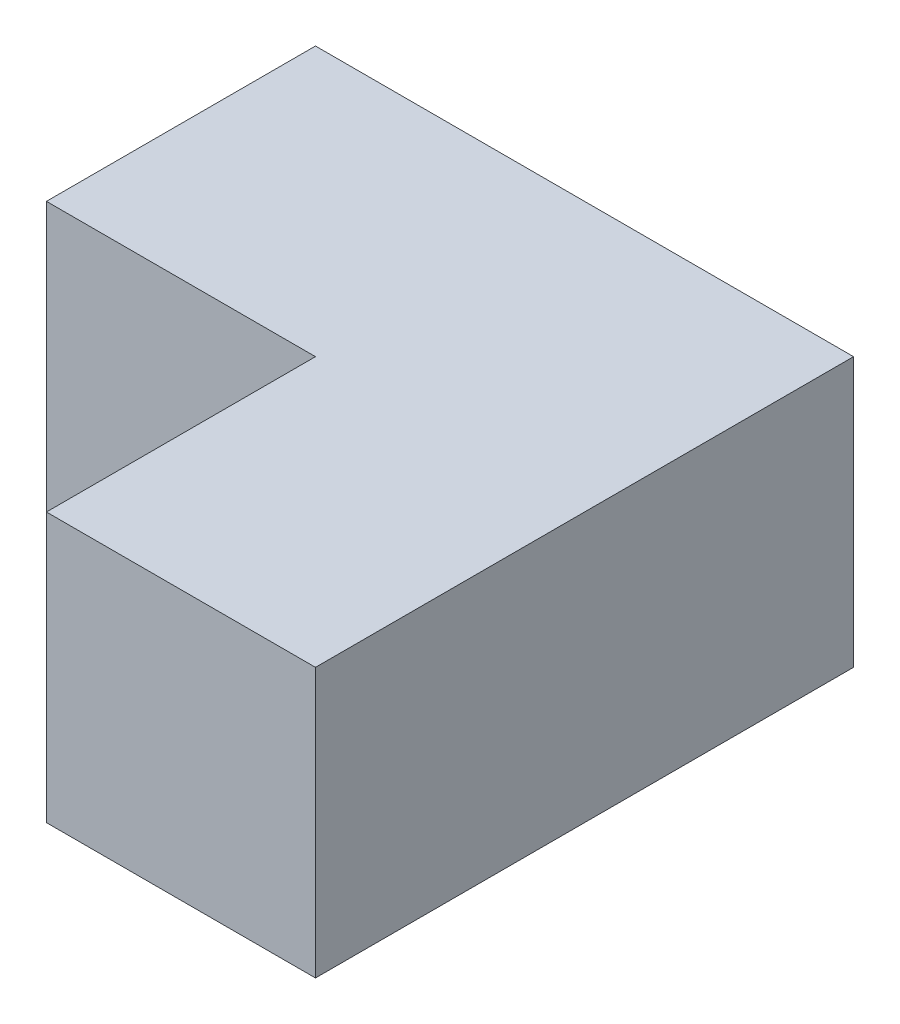
from build123d import *

# Parameters (mm, degrees)
SKETCH1_W           = 50.8
SKETCH1_H           = 50.8
BOSS_EXTRUDE1_DEPTH = 25.4
SKETCH2_W           = 25.4
SKETCH2_H           = 25.4
CUT_EXTRUDE1_DEPTH  = 26.4


with BuildPart() as part:
    # Sketch1 → Boss-Extrude1 (new body)
    with BuildSketch(Plane(origin=(0, 0, 0), x_dir=(1, 0, 0), z_dir=(0, 1, 0))):
        Rectangle(SKETCH1_W, SKETCH1_H)
    extrude(amount=BOSS_EXTRUDE1_DEPTH)

    # Sketch2 → Cut-Extrude1 (cut, through all)
    with BuildSketch(Plane(origin=(0, 25.4, 0), x_dir=(1, 0, 0), z_dir=(0, 1, 0))):
        with Locations((-12.7, -12.7)):
            Rectangle(SKETCH2_W, SKETCH2_H)
    extrude(amount=-CUT_EXTRUDE1_DEPTH, mode=Mode.SUBTRACT)


solid = part.part
